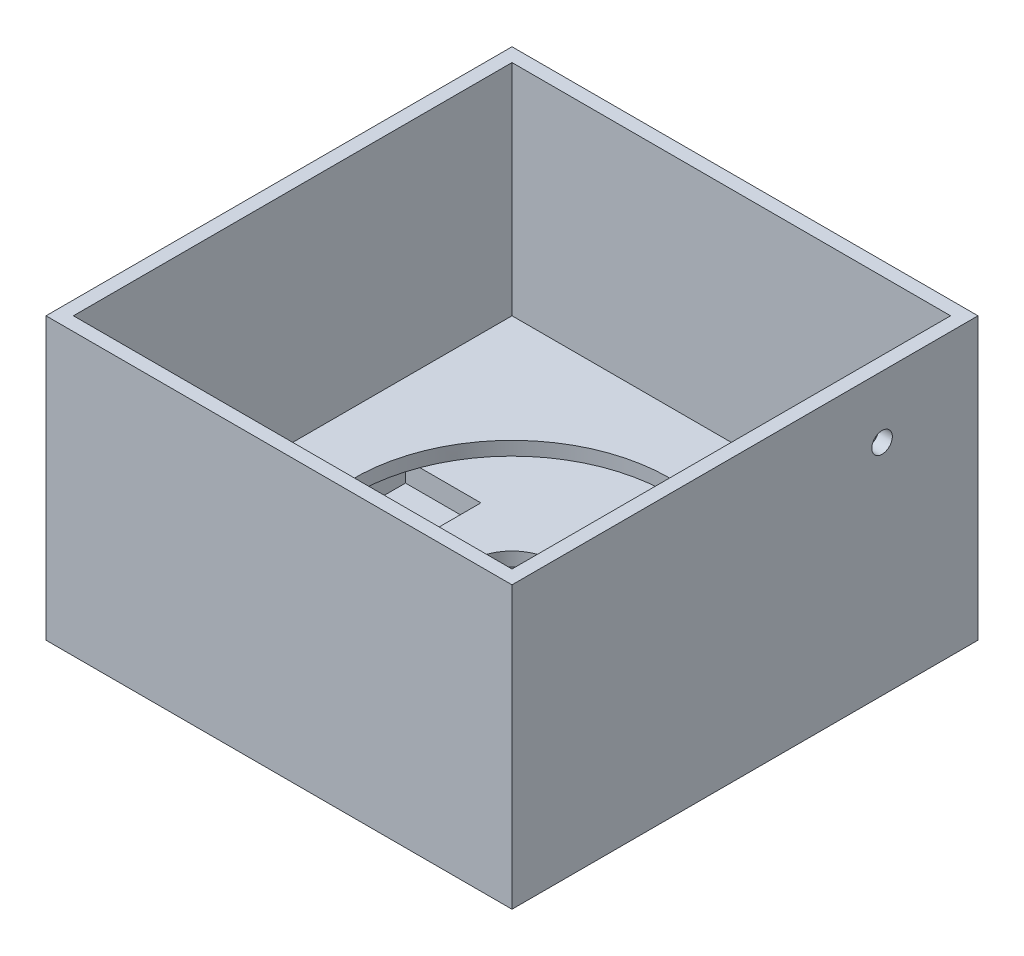
from build123d import *

# Parameters (mm, degrees)
SKETCH1_W           = 68
SKETCH1_H           = 68
BOSS_EXTRUDE1_DEPTH = 41
CUT_EXTRUDE1_START  = 41
SKETCH2_W           = 64
SKETCH2_H           = 64
CUT_EXTRUDE1_DEPTH  = 32
CUT_EXTRUDE4_START  = 9
SKETCH3_R           = 23
CUT_EXTRUDE4_DEPTH  = 2
CUT_EXTRUDE9_START  = 7
SKETCH5_R           = 6.05
CUT_EXTRUDE9_DEPTH  = 8
SKETCH6_R           = 10.5
CUT_EXTRUDE10_DEPTH = 5
SKETCH7_W           = 30
SKETCH7_H           = 30
SKETCH7_W_2         = 26
SKETCH7_H_2         = 26
CUT_EXTRUDE11_DEPTH = 2
SKETCH8_R           = 1.5
CUT_EXTRUDE12_DEPTH = 3
SKETCH4_W           = 11
SKETCH4_H           = 16
SKETCH4_R           = 1.75
CUT_EXTRUDE13_DEPTH = 3


with BuildPart() as part:
    # Sketch1 → Boss-Extrude1 (new body)
    with BuildSketch(Plane(origin=(0, 0, 0), x_dir=(1, 0, 0), z_dir=(0, 1, 0))):
        Rectangle(SKETCH1_W, SKETCH1_H)
    extrude(amount=BOSS_EXTRUDE1_DEPTH)

    # Sketch2 → Cut-Extrude1 (cut)
    with BuildSketch(Plane(origin=(0, 0, 0), x_dir=(1, 0, 0), z_dir=(0, 1, 0)).offset(CUT_EXTRUDE1_START)):
        Rectangle(SKETCH2_W, SKETCH2_H)
    extrude(amount=-CUT_EXTRUDE1_DEPTH, mode=Mode.SUBTRACT)

    # Sketch3 → Cut-Extrude4 (cut)
    with BuildSketch(Plane(origin=(0, 0, 0), x_dir=(1, 0, 0), z_dir=(0, 1, 0)).offset(CUT_EXTRUDE4_START)):
        Circle(SKETCH3_R)
    extrude(amount=-CUT_EXTRUDE4_DEPTH, mode=Mode.SUBTRACT)

    # Sketch5 → Cut-Extrude9 (cut, through all)
    with BuildSketch(Plane(origin=(0, 0, 0), x_dir=(1, 0, 0), z_dir=(0, 1, 0)).offset(CUT_EXTRUDE9_START)):
        Circle(SKETCH5_R)
    extrude(amount=-CUT_EXTRUDE9_DEPTH, mode=Mode.SUBTRACT)

    # Sketch6 → Cut-Extrude10 (cut)
    with BuildSketch(Plane.XZ):
        Circle(SKETCH6_R)
    extrude(amount=-CUT_EXTRUDE10_DEPTH, mode=Mode.SUBTRACT)

    # Sketch7 → Cut-Extrude11 (cut)
    with BuildSketch(Plane(origin=(0, 0, 0), x_dir=(-1, 0, 0), z_dir=(0, -1, 0))):
        Rectangle(SKETCH7_W, SKETCH7_H)
        Rectangle(SKETCH7_W_2, SKETCH7_H_2, mode=Mode.SUBTRACT)
    extrude(amount=-CUT_EXTRUDE11_DEPTH, mode=Mode.SUBTRACT)

    # Sketch8 → Cut-Extrude12 (cut, through all)
    with BuildSketch(Plane.ZY.offset(-32)):
        with Locations((-20, 32)):
            Circle(SKETCH8_R)
    extrude(amount=-CUT_EXTRUDE12_DEPTH, mode=Mode.SUBTRACT)

    # Sketch4 → Cut-Extrude13 (cut)
    with BuildSketch(Plane(origin=(0, 7, 0), x_dir=(1, 0, 0), z_dir=(0, 1, 0))):
        with Locations((-18.125903529, 0.086164087)):
            Rectangle(SKETCH4_W, SKETCH4_H)
        with Locations((-16.625903529, 0.086164087)):
            Circle(SKETCH4_R, mode=Mode.SUBTRACT)
    extrude(amount=-CUT_EXTRUDE13_DEPTH, mode=Mode.SUBTRACT)


solid = part.part
